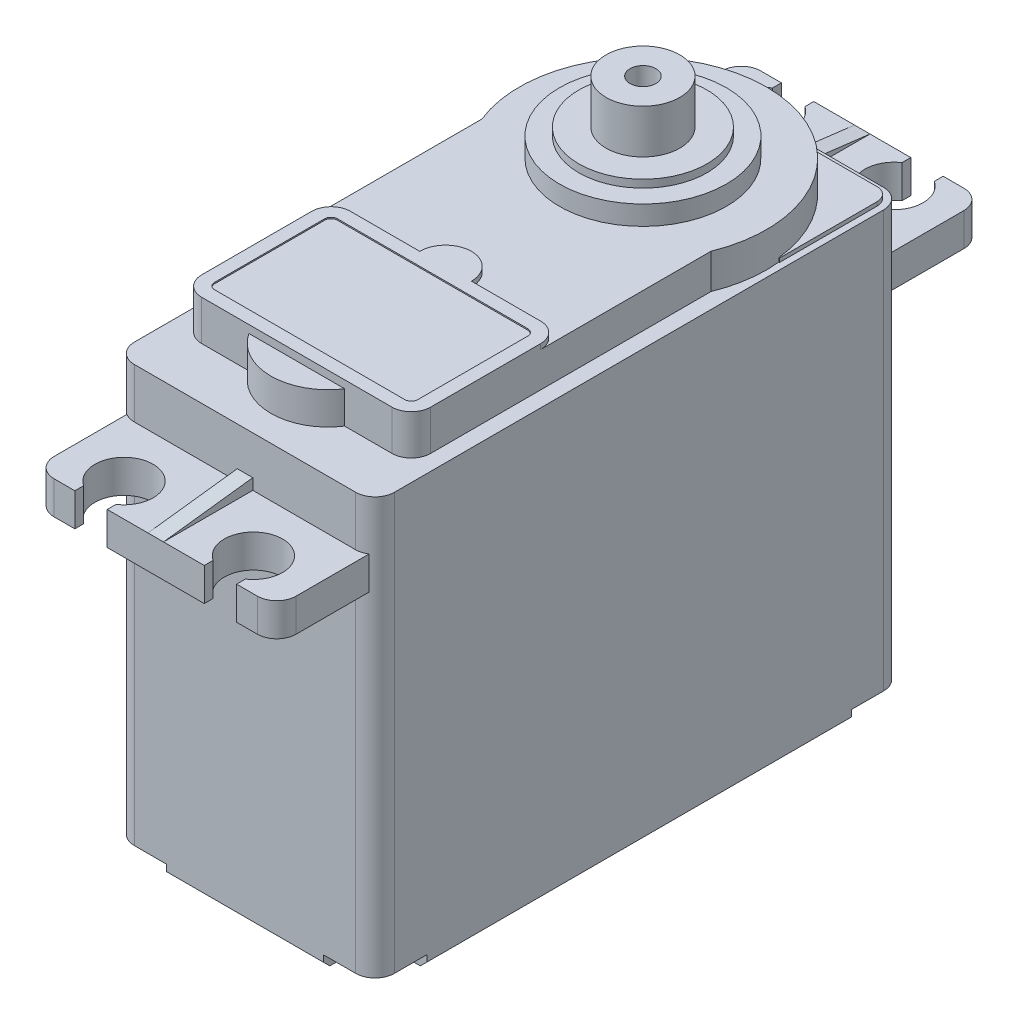
from build123d import *

# Parameters (mm, degrees)
BOSS_EXTRUDE1_DEPTH  = 33.2
BOSS_EXTRUDE2_DEPTH  = 2.55
BOSS_EXTRUDE11_DEPTH = 0.3
BOSS_EXTRUDE3_DEPTH  = 2.7
SKETCH6_R            = 4.4225
BOSS_EXTRUDE4_DEPTH  = 2.5
SKETCH7_R            = 6.45
BOSS_EXTRUDE5_DEPTH  = 1.5
SKETCH8_R            = 4.95
BOSS_EXTRUDE6_DEPTH  = 0.6
SKETCH10_R           = 2.85
BOSS_EXTRUDE7_DEPTH  = 3.4
SKETCH12_R           = 1
CUT_EXTRUDE1_DEPTH   = 5
BOSS_EXTRUDE9_DEPTH  = 0.4
BOSS_EXTRUDE10_DEPTH = 0.3
CHAMFER1_SIZE        = 0.5
CUT_EXTRUDE2_DEPTH   = 1
MIRROR2_COPY_1_DEPTH = 1
BOSS_EXTRUDE12_DEPTH = 0.6


with BuildPart() as part:
    # Sketch1 → Boss-Extrude1 (new body)
    with BuildSketch(Plane(origin=(0, 0, 0), x_dir=(1, 0, 0), z_dir=(0, 1, 0))):
        with BuildLine():
            Line((-8.55, -25.58), (8.55, -25.58))
            ThreePointArc((8.55, -25.58), (9.610660172, -25.140660172), (10.05, -24.08))
            Line((10.05, -24.08), (10.05, 13.72))
            ThreePointArc((10.05, 13.72), (9.610660172, 14.780660172), (8.55, 15.22))
            Line((8.55, 15.22), (-8.55, 15.22))
            ThreePointArc((-8.55, 15.22), (-9.610660172, 14.780660172), (-10.05, 13.72))
            Line((-10.05, 13.72), (-10.05, -24.08))
            ThreePointArc((-10.05, -24.08), (-9.610660172, -25.140660172), (-8.55, -25.58))
        make_face()
    extrude(amount=BOSS_EXTRUDE1_DEPTH)

    # Sketch4 → Boss-Extrude2 (add)
    with BuildSketch(Plane(origin=(0, 26.8, 0), x_dir=(1, 0, 0), z_dir=(0, 1, 0))):
        with BuildLine():
            Line((-6.25, 22.12), (-6.25, 21.440828693))
            ThreePointArc((-6.25, 21.440828693), (-5, 17.32), (-3.75, 21.440828693))
            Line((-3.75, 21.440828693), (-3.75, 22.12))
            Line((-3.75, 22.12), (3.75, 22.12))
            Line((3.75, 22.12), (3.75, 21.440828693))
            ThreePointArc((3.75, 21.440828693), (5, 17.32), (6.25, 21.440828693))
            Line((6.25, 21.440828693), (6.25, 22.12))
            Line((6.25, 22.12), (7.85, 22.12))
            ThreePointArc((7.85, 22.12), (8.910660172, 21.680660172), (9.35, 20.62))
            Line((9.35, 20.62), (9.35, -30.98))
            ThreePointArc((9.35, -30.98), (8.910660172, -32.040660172), (7.85, -32.48))
            Line((7.85, -32.48), (6.25, -32.48))
            Line((6.25, -32.48), (6.25, -31.800828693))
            ThreePointArc((6.25, -31.800828693), (5, -27.68), (3.75, -31.800828693))
            Line((3.75, -31.800828693), (3.75, -32.48))
            Line((3.75, -32.48), (-3.75, -32.48))
            Line((-3.75, -32.48), (-3.75, -31.800828693))
            ThreePointArc((-3.75, -31.800828693), (-5, -27.68), (-6.25, -31.800828693))
            Line((-6.25, -31.800828693), (-6.25, -32.48))
            Line((-6.25, -32.48), (-7.85, -32.48))
            ThreePointArc((-7.85, -32.48), (-8.910660172, -32.040660172), (-9.35, -30.98))
            Line((-9.35, -30.98), (-9.35, 20.62))
            ThreePointArc((-9.35, 20.62), (-8.910660172, 21.680660172), (-7.85, 22.12))
            Line((-7.85, 22.12), (-6.25, 22.12))
        make_face()
    extrude(amount=BOSS_EXTRUDE2_DEPTH)

    # Sketch16 → Boss-Extrude11 (add)
    with BuildSketch(Plane(origin=(0, 33.2, 0), x_dir=(1, 0, 0), z_dir=(0, 1, 0))):
        with BuildLine():
            Line((-9.55, 13.72), (-9.55, 6.17))
            Line((-9.55, 6.17), (9.55, 6.17))
            Line((9.55, 6.17), (9.55, 13.72))
            ThreePointArc((9.55, 13.72), (9.257106781, 14.427106781), (8.55, 14.72))
            Line((8.55, 14.72), (-8.55, 14.72))
            ThreePointArc((-8.55, 14.72), (-9.257106781, 14.427106781), (-9.55, 13.72))
        make_face()
    extrude(amount=BOSS_EXTRUDE11_DEPTH)

    # Sketch5 → Boss-Extrude3 (add)
    with BuildSketch(Plane(origin=(0, 33.2, 0), x_dir=(1, 0, 0), z_dir=(0, 1, 0))):
        with BuildLine():
            Line((-8.85, 1.581128311), (-8.85, -20.08))
            ThreePointArc((-8.85, -20.08), (-8.410660172, -21.140660172), (-7.35, -21.58))
            Line((-7.35, -21.58), (7.35, -21.58))
            ThreePointArc((7.35, -21.58), (8.410660172, -21.140660172), (8.85, -20.08))
            Line((8.85, -20.08), (8.85, 1.581128311))
            ThreePointArc((8.85, 1.581128311), (0, 14.72), (-8.85, 1.581128311))
        make_face()
    extrude(amount=BOSS_EXTRUDE3_DEPTH)

    # Sketch6 → Boss-Extrude4 (add)
    with BuildSketch(Plane(origin=(0, 33.2, 0), x_dir=(1, 0, 0), z_dir=(0, 1, 0))):
        with Locations((0, -19.1575)):
            Circle(SKETCH6_R)
    extrude(amount=BOSS_EXTRUDE4_DEPTH)

    # Sketch7 → Boss-Extrude5 (add)
    with BuildSketch(Plane(origin=(0, 35.9, 0), x_dir=(1, 0, 0), z_dir=(0, 1, 0))):
        with Locations((0, 5.17)):
            Circle(SKETCH7_R)
    extrude(amount=BOSS_EXTRUDE5_DEPTH)

    # Sketch8 → Boss-Extrude6 (add)
    with BuildSketch(Plane(origin=(0, 37.4, 0), x_dir=(1, 0, 0), z_dir=(0, 1, 0))):
        with Locations((0, 5.17)):
            Circle(SKETCH8_R)
    extrude(amount=BOSS_EXTRUDE6_DEPTH)

    # Sketch10 → Boss-Extrude7 (add)
    with BuildSketch(Plane(origin=(0, 38, 0), x_dir=(1, 0, 0), z_dir=(0, 1, 0))):
        with Locations((0, 5.17)):
            Circle(SKETCH10_R)
    extrude(amount=BOSS_EXTRUDE7_DEPTH)

    # Sketch12 → Cut-Extrude1 (cut)
    with BuildSketch(Plane(origin=(0, 41.4, 0), x_dir=(1, 0, 0), z_dir=(0, 1, 0))):
        with Locations((0, 5.17)):
            Circle(SKETCH12_R)
    extrude(amount=-CUT_EXTRUDE1_DEPTH, mode=Mode.SUBTRACT)

    # Sketch13 → Boss-Extrude9 (add)
    with BuildSketch(Plane(origin=(0, 35.9, 0), x_dir=(1, 0, 0), z_dir=(0, 1, 0))):
        with BuildLine():
            Line((-8.85, -11.58), (-8.85, -20.08))
            ThreePointArc((-8.85, -20.08), (-8.410660172, -21.140660172), (-7.35, -21.58))
            Line((-7.35, -21.58), (7.35, -21.58))
            ThreePointArc((7.35, -21.58), (8.410660172, -21.140660172), (8.85, -20.08))
            Line((8.85, -20.08), (8.85, -11.58))
            ThreePointArc((8.85, -11.58), (8.410660172, -10.519339828), (7.35, -10.08))
            Line((7.35, -10.08), (2, -10.08))
            ThreePointArc((2, -10.08), (0, -8.08), (-2, -10.08))
            Line((-2, -10.08), (-7.35, -10.08))
            ThreePointArc((-7.35, -10.08), (-8.410660172, -10.519339828), (-8.85, -11.58))
        make_face()
        with BuildLine():
            Line((-7.85, -11.58), (-7.85, -20.08))
            ThreePointArc((-7.85, -20.08), (-7.703553391, -20.433553391), (-7.35, -20.58))
            Line((-7.35, -20.58), (7.35, -20.58))
            ThreePointArc((7.35, -20.58), (7.703553391, -20.433553391), (7.85, -20.08))
            Line((7.85, -20.08), (7.85, -11.58))
            ThreePointArc((7.85, -11.58), (7.703553391, -11.226446609), (7.35, -11.08))
            Line((7.35, -11.08), (-7.35, -11.08))
            ThreePointArc((-7.35, -11.08), (-7.703553391, -11.226446609), (-7.85, -11.58))
        make_face(mode=Mode.SUBTRACT)
    extrude(amount=BOSS_EXTRUDE9_DEPTH)

    # Sketch14 → Boss-Extrude10 (add)
    with BuildSketch(Plane(origin=(0, 35.9, 0), x_dir=(1, 0, 0), z_dir=(0, 1, 0))):
        with BuildLine():
            Line((-7.85, -11.58), (-7.85, -20.08))
            ThreePointArc((-7.85, -20.08), (-7.703553391, -20.433553391), (-7.35, -20.58))
            Line((-7.35, -20.58), (7.35, -20.58))
            ThreePointArc((7.35, -20.58), (7.703553391, -20.433553391), (7.85, -20.08))
            Line((7.85, -20.08), (7.85, -11.58))
            ThreePointArc((7.85, -11.58), (7.703553391, -11.226446609), (7.35, -11.08))
            Line((7.35, -11.08), (-7.35, -11.08))
            ThreePointArc((-7.35, -11.08), (-7.703553391, -11.226446609), (-7.85, -11.58))
        make_face()
    extrude(amount=BOSS_EXTRUDE10_DEPTH)

    # Chamfer1
    chamfer1_edges = [part.edges().sort_by_distance(p)[0] for p in [
        (-10.05, 0, 5.18),
        (-9.610660172, 0, -14.780660172),
        (0, 0, -15.22),
        (9.610660172, 0, -14.780660172),
        (10.05, 0, 5.18),
        (9.610660172, 0, 25.140660172),
        (0, 0, 25.58),
        (-9.610660172, 0, 25.140660172),
    ]]
    chamfer(chamfer1_edges, length=CHAMFER1_SIZE)

    # Sketch17 → Cut-Extrude2 (cut)
    with BuildSketch(Plane.XZ):
        with BuildLine():
            Line((-10.05, 21.58), (-10.05, 24.08))
            ThreePointArc((-10.05, 24.08), (-9.610660172, 25.140660172), (-8.55, 25.58))
            Line((-8.55, 25.58), (-6.05, 25.58))
            Line((-6.05, 25.58), (-6.05, 23.08))
            ThreePointArc((-6.05, 23.08), (-6.489339828, 22.019339828), (-7.55, 21.58))
            Line((-7.55, 21.58), (-10.05, 21.58))
        make_face()
    cut_extrude2 = extrude(amount=-CUT_EXTRUDE2_DEPTH, mode=Mode.SUBTRACT)

    # Mirror1: Cut-Extrude2 across plane
    add(cut_extrude2.mirror(Plane(origin=(0, 0, 0), x_dir=(0, 0, 1), z_dir=(1, 0, 0))), mode=Mode.SUBTRACT)

    # Mirror2: Cut-Extrude2 across plane
    add(cut_extrude2.mirror(Plane.XY.offset(5.18)), mode=Mode.SUBTRACT)

    # Mirror2 copy 1 sketch → Mirror2 copy 1 (cut)
    with BuildSketch(Plane(origin=(0, 0, 10.36), x_dir=(-1, 0, 0), z_dir=(0, -1, 0))):
        with BuildLine():
            Line((-10.05, 21.58), (-10.05, 24.08))
            ThreePointArc((-10.05, 24.08), (-9.610660172, 25.140660172), (-8.55, 25.58))
            Line((-8.55, 25.58), (-6.05, 25.58))
            Line((-6.05, 25.58), (-6.05, 23.08))
            ThreePointArc((-6.05, 23.08), (-6.489339828, 22.019339828), (-7.55, 21.58))
            Line((-7.55, 21.58), (-10.05, 21.58))
        make_face()
    extrude(amount=-MIRROR2_COPY_1_DEPTH, mode=Mode.SUBTRACT)

    # Sketch19 → Boss-Extrude12 (add, symmetric)
    with BuildSketch(Plane(origin=(0, 0, 0), x_dir=(0, 0, -1), z_dir=(1, 0, 0))):
        Polygon((-25.58, 30.2), (-25.58, 29.35), (-32.48, 29.35), align=None)
        Polygon((15.22, 30.2), (15.22, 29.35), (22.12, 29.35), align=None)
    extrude(amount=BOSS_EXTRUDE12_DEPTH, both=True)


solid = part.part
